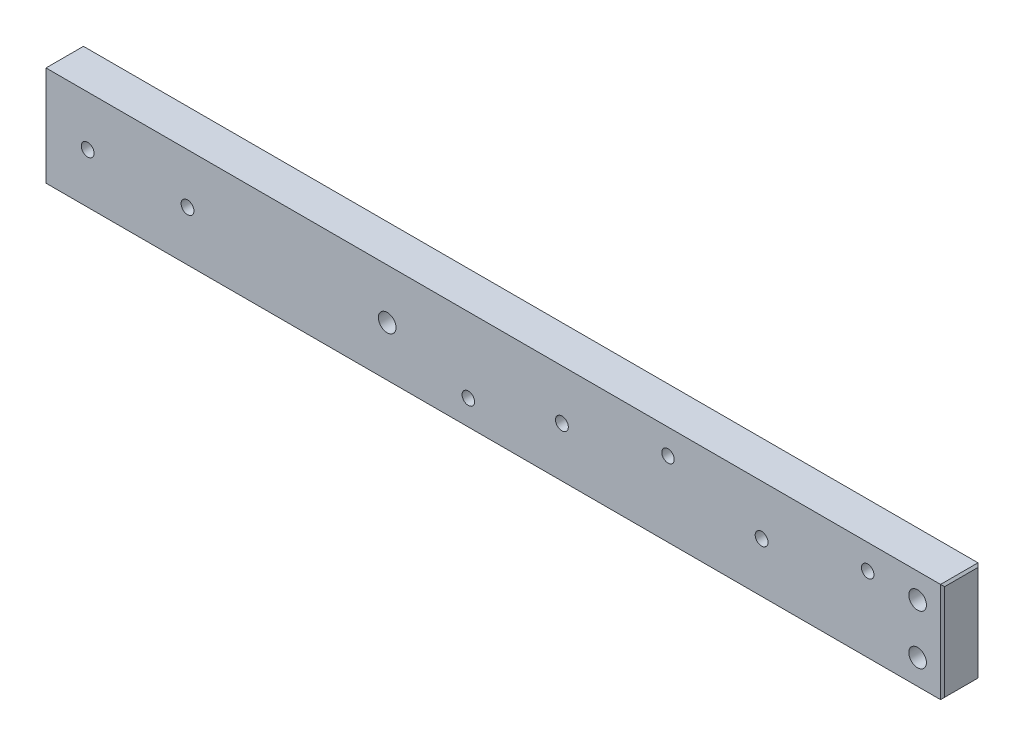
from build123d import *

# Parameters (mm, degrees)
SKETCH1_W                        = 228.6
SKETCH1_H                        = 25.4
BOSS_EXTRUDE1_DEPTH              = 9.525
F_8_CLEARANCE_HOLE1_D            = 4.4958
F_8_CLEARANCE_HOLE1_DEPTH        = 25.4
F_8_CLEARANCE_HOLE1_TIP          = 1.350674586
F_8_CLEARANCE_HOLE2_D            = 4.4958
F_8_CLEARANCE_HOLE2_DEPTH        = 19.05
F_8_CLEARANCE_HOLE2_TIP          = 1.350674586
CHAMFER1_SIZE                    = 0.508
F_4_CLEARANCE_HOLE1_D            = 3.2639
F_4_CLEARANCE_HOLE2_D            = 3.2639
F_4_CLEARANCE_HOLE2_DEPTH        = 9.525
F_1_8_0_125_DIAMETER_HOLE1_D     = 3.175
F_1_8_0_125_DIAMETER_HOLE1_DEPTH = 9.525


with BuildPart() as part:
    # Sketch1 → Boss-Extrude1 (new body)
    with BuildSketch(Plane.XY):
        with Locations((-114.3, 12.7)):
            Rectangle(SKETCH1_W, SKETCH1_H)
    extrude(amount=BOSS_EXTRUDE1_DEPTH)

    # #8 Clearance Hole1
    with Locations(Plane.XY.offset(9.525)):
        with Locations((-6.35, 6.35), (-6.35, 19.05)):
            Hole(F_8_CLEARANCE_HOLE1_D / 2, depth=F_8_CLEARANCE_HOLE1_DEPTH)
            with Locations((0, 0, -(F_8_CLEARANCE_HOLE1_DEPTH + F_8_CLEARANCE_HOLE1_TIP / 2))):  # 118° drill point
                Cone(0, F_8_CLEARANCE_HOLE1_D / 2, F_8_CLEARANCE_HOLE1_TIP, mode=Mode.SUBTRACT)

    # #8 Clearance Hole2
    with Locations(Plane.XY.offset(9.525)):
        with Locations((-141.2875, 12.7)):
            Hole(F_8_CLEARANCE_HOLE2_D / 2, depth=F_8_CLEARANCE_HOLE2_DEPTH)
            with Locations((0, 0, -(F_8_CLEARANCE_HOLE2_DEPTH + F_8_CLEARANCE_HOLE2_TIP / 2))):  # 118° drill point
                Cone(0, F_8_CLEARANCE_HOLE2_D / 2, F_8_CLEARANCE_HOLE2_TIP, mode=Mode.SUBTRACT)

    # Chamfer1
    chamfer1_edges = [part.edges().sort_by_distance(p)[0] for p in [
        (-228.6, 12.7, 9.525),
        (0, 12.7, 9.525),
        (-228.6, 12.7, 0),
        (0, 12.7, 0),
        (0, 0, 4.7625),
        (-228.6, 0, 4.7625),
        (-228.6, 25.4, 4.7625),
        (0, 25.4, 4.7625),
    ]]
    chamfer(chamfer1_edges, length=CHAMFER1_SIZE)

    # #4 Clearance Hole1 (through all)
    with Locations(Plane(origin=(0, 0, 0), x_dir=(-1, 0, 0), z_dir=(0, 0, -1))):
        with Locations((96.8375, 12.7), (46.0375, 12.7)):
            Hole(F_4_CLEARANCE_HOLE1_D / 2)

    # #4 Clearance Hole2
    with Locations(Plane.XY.offset(9.525)):
        with Locations((-217.4875, 12.7), (-192.0875, 12.7)):
            Hole(F_4_CLEARANCE_HOLE2_D / 2, depth=F_4_CLEARANCE_HOLE2_DEPTH)

    # 1/8 (0.125) Diameter Hole1
    with Locations(Plane.XY.offset(9.525)):
        with Locations((-19.05, 19.05), (-69.85, 19.05), (-120.65, 6.35)):
            Hole(F_1_8_0_125_DIAMETER_HOLE1_D / 2, depth=F_1_8_0_125_DIAMETER_HOLE1_DEPTH)


solid = part.part
